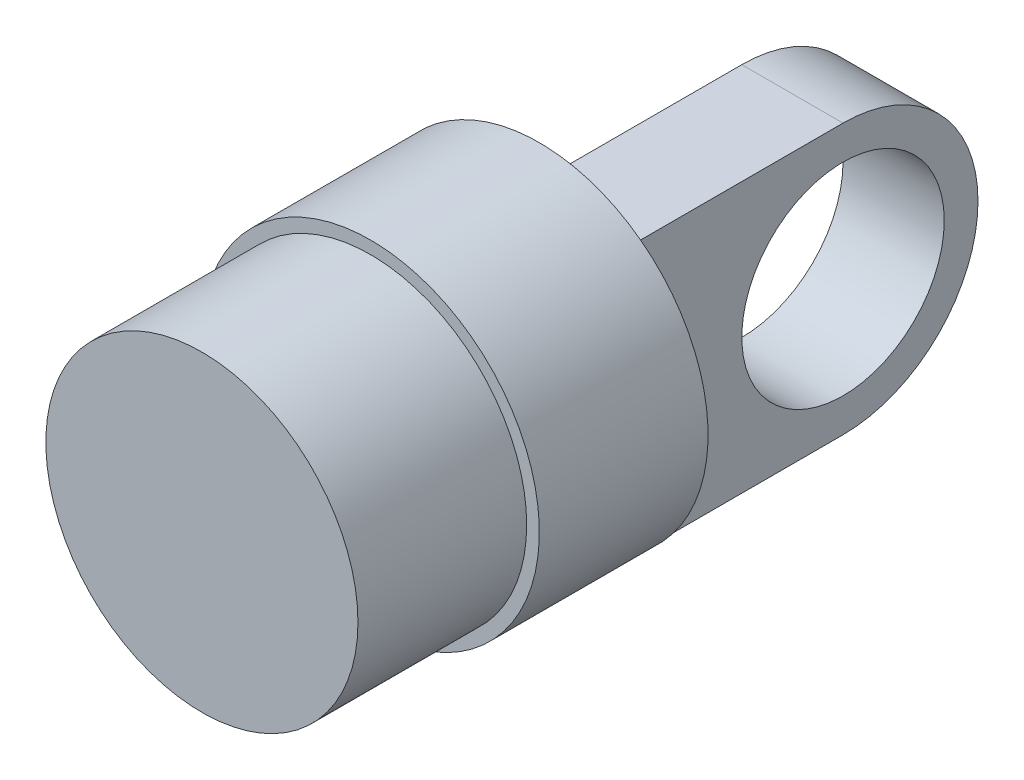
from build123d import *

# Parameters (mm, degrees)
SKETCH1_R               = 9.25
BOSS_EXTRUDE1_DEPTH     = 10
SKETCH2_R               = 10
BOSS_EXTRUDE2_DEPTH     = 10
SKETCH3_W               = 12
SKETCH3_H               = 16
BOSS_EXTRUDE3_DEPTH     = 20
CUT_EXTRUDE1_DEPTH      = 36.440090293
CUT_EXTRUDE1_DEPTH_BACK = 30
SKETCH4_3_R             = 6
CUT_EXTRUDE2_DEPTH      = 36.440090293
SKETCH5_W               = 6
SKETCH5_H               = 20
CUT_EXTRUDE3_DEPTH      = 37.386810797


with BuildPart() as part:
    # Sketch1 → Boss-Extrude1 (new body)
    with BuildSketch(Plane.XY):
        Circle(SKETCH1_R)
    extrude(amount=BOSS_EXTRUDE1_DEPTH)

    # Sketch2 → Boss-Extrude2 (add)
    with BuildSketch(Plane(origin=(0, 0, 0), x_dir=(-1, 0, 0), z_dir=(0, 0, -1))):
        Circle(SKETCH2_R)
    extrude(amount=BOSS_EXTRUDE2_DEPTH)

    # Sketch3 → Boss-Extrude3 (add)
    with BuildSketch(Plane(origin=(0, 0, -10), x_dir=(-1, 0, 0), z_dir=(0, 0, -1))):
        Rectangle(SKETCH3_W, SKETCH3_H)
    extrude(amount=BOSS_EXTRUDE3_DEPTH)

    # Sketch4 → Cut-Extrude1 (cut, two sides: drawn at the far end of the back side and taken through both)
    with BuildSketch(Plane(origin=(6, 0, 0), x_dir=(0, 0, -1), z_dir=(1, 0, 0)).offset(-CUT_EXTRUDE1_DEPTH_BACK)):
        with BuildLine():
            Line((30, 8), (22, 8))
            ThreePointArc((22, 8), (27.656854249, 5.656854249), (30, 0))
            Line((30, 0), (30, 8))
        make_face()
        with BuildLine():
            Line((30, -8), (30, 0))
            ThreePointArc((30, 0), (27.656854249, -5.656854249), (22, -8))
            Line((22, -8), (30, -8))
        make_face()
    extrude(amount=CUT_EXTRUDE1_DEPTH + CUT_EXTRUDE1_DEPTH_BACK, mode=Mode.SUBTRACT)

    # Sketch4_3 → Cut-Extrude2 (cut, through all)
    with BuildSketch(Plane(origin=(6, 0, 0), x_dir=(0, 0, -1), z_dir=(1, 0, 0))):
        with Locations((22, 0)):
            Circle(SKETCH4_3_R)
    extrude(amount=-CUT_EXTRUDE2_DEPTH, mode=Mode.SUBTRACT)

    # Sketch5 → Cut-Extrude3 (cut, through all)
    with BuildSketch(Plane(origin=(0, 8, 0), x_dir=(1, 0, 0), z_dir=(0, 1, 0))):
        with Locations((-3, 20)):
            Rectangle(SKETCH5_W, SKETCH5_H)
    extrude(amount=-CUT_EXTRUDE3_DEPTH, mode=Mode.SUBTRACT)


solid = part.part
